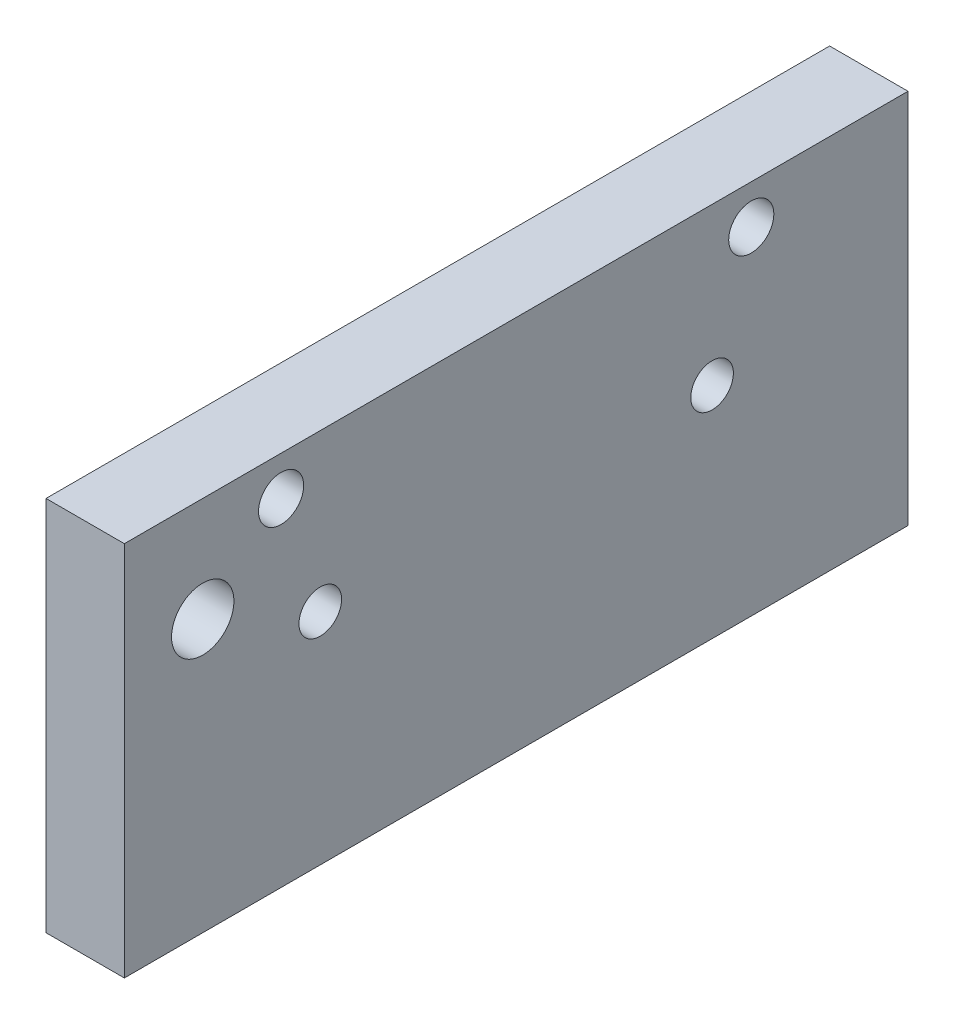
from build123d import *

# Parameters (mm, degrees)
SKETCH1_W                                  = 63.5
SKETCH1_H                                  = 30.48
BOSS_EXTRUDE1_DEPTH                        = 6.35
TAP_DRILL_FOR_8_32_TAP1_D                  = 3.4544
TAP_DRILL_FOR_8_32_TAP1_DEPTH              = 6.35
TAP_DRILL_FOR_8_32_TAP1_TIP                = 1.037806461
F_6_CLOSE_CLEARANCE_HOLE_COUNTERSINK_D     = 3.6576
F_6_CLOSE_CLEARANCE_HOLE_COUNTERSINK_DEPTH = 6.35
F_8_THROUGH_HOLE_D                         = 5.0546
F_8_THROUGH_HOLE_DEPTH                     = 6.35
F_8_THROUGH_HOLE_TIP                       = 1.518555042


with BuildPart() as part:
    # Sketch1 → Boss-Extrude1 (new body)
    with BuildSketch(Plane(origin=(0, 0, 0), x_dir=(0, 0, -1), z_dir=(1, 0, 0))):
        with Locations((-28.514872299, 20.201128374)):
            Rectangle(SKETCH1_W, SKETCH1_H)
    extrude(amount=BOSS_EXTRUDE1_DEPTH)

    # Tap Drill for #8-32 Tap1
    with Locations(Plane.ZY):
        with Locations((12.639872299, 22.741128374), (44.389872299, 22.741128374)):
            Hole(TAP_DRILL_FOR_8_32_TAP1_D / 2, depth=TAP_DRILL_FOR_8_32_TAP1_DEPTH)
            with Locations((0, 0, -(TAP_DRILL_FOR_8_32_TAP1_DEPTH + TAP_DRILL_FOR_8_32_TAP1_TIP / 2))):  # 118° drill point
                Cone(0, TAP_DRILL_FOR_8_32_TAP1_D / 2, TAP_DRILL_FOR_8_32_TAP1_TIP, mode=Mode.SUBTRACT)

    # #6 Close clearance hole, countersink
    with Locations(Plane.ZY):
        with Locations((9.464872299, 32.266128374), (47.564872299, 32.266128374)):
            Hole(F_6_CLOSE_CLEARANCE_HOLE_COUNTERSINK_D / 2, depth=F_6_CLOSE_CLEARANCE_HOLE_COUNTERSINK_DEPTH)

    # #8 Through hole
    with Locations(Plane.ZY):
        with Locations((53.914872299, 26.974461707)):
            Hole(F_8_THROUGH_HOLE_D / 2, depth=F_8_THROUGH_HOLE_DEPTH)
            with Locations((0, 0, -(F_8_THROUGH_HOLE_DEPTH + F_8_THROUGH_HOLE_TIP / 2))):  # 118° drill point
                Cone(0, F_8_THROUGH_HOLE_D / 2, F_8_THROUGH_HOLE_TIP, mode=Mode.SUBTRACT)


solid = part.part
